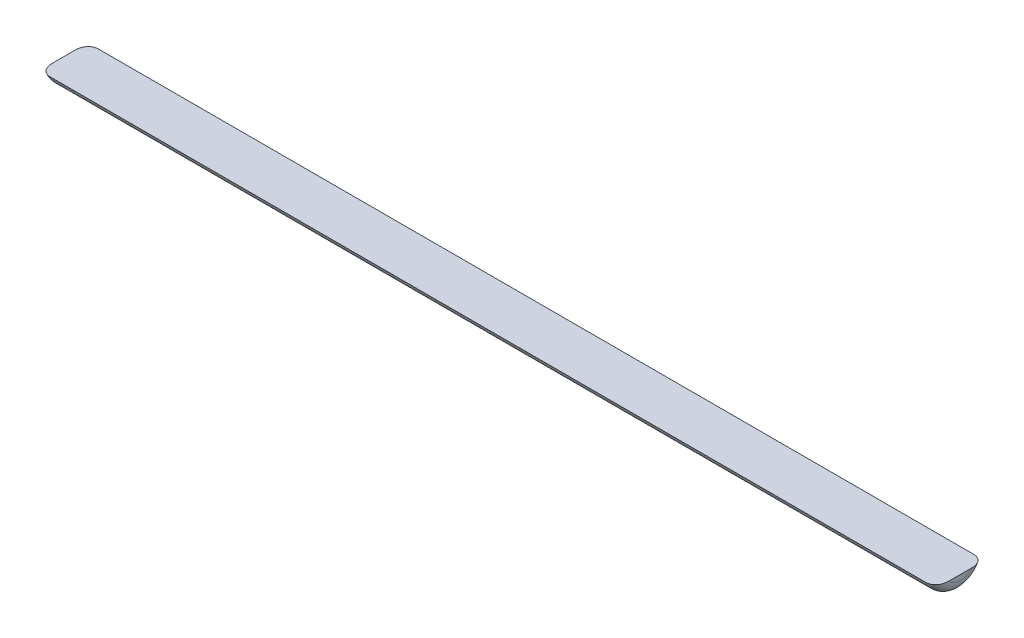
from build123d import *

# Parameters (mm, degrees)
BOSS_EXTRUDE1_DEPTH = 170
FILLET1_R           = 2


with BuildPart() as part:
    # Sketch1 → Boss-Extrude1 (new body)
    with BuildSketch(Plane(origin=(0, 0, 0), x_dir=(0, 0, -1), z_dir=(1, 0, 0))):
        with BuildLine():
            Line((-4.575, -2.017269194), (4.575, -2.017269194))
            ThreePointArc((4.575, -2.017269194), (0, -5), (-4.575, -2.017269194))
        make_face()
    extrude(amount=BOSS_EXTRUDE1_DEPTH)

    # Fillet1
    fillet1_edges = [part.edges().sort_by_distance(p)[0] for p in [
        (0, -5, 0),
        (170, -5, 0),
    ]]
    fillet(fillet1_edges, radius=FILLET1_R)


solid = part.part
